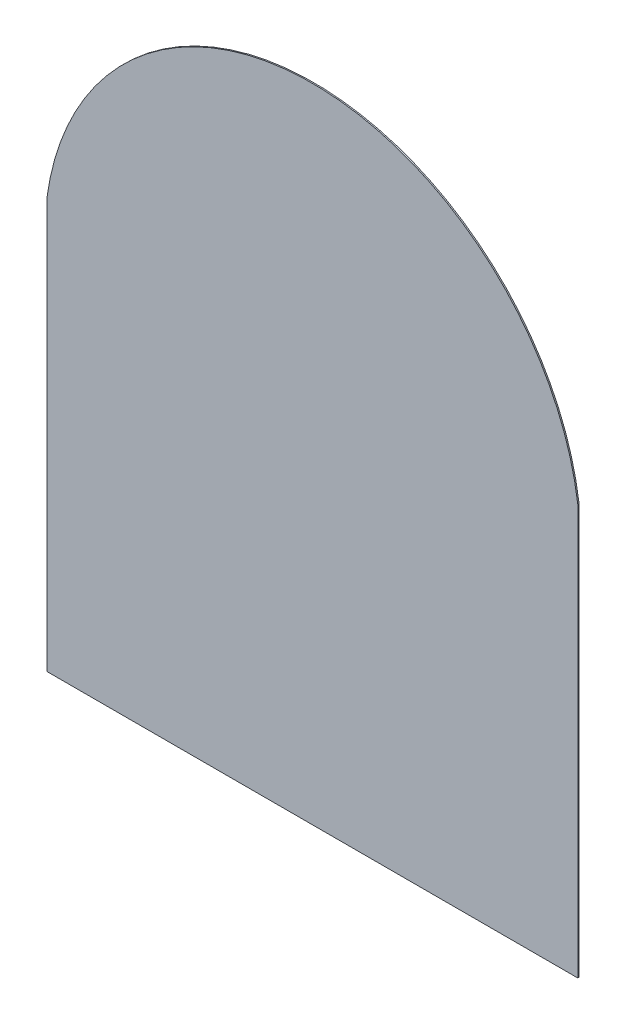
from build123d import *

# Parameters (mm, degrees)
BOSS_EXTRUDE1_DEPTH = 2.5


with BuildPart() as part:
    # Sketch1 → Boss-Extrude1 (new body, symmetric)
    with BuildSketch(Plane.XY):
        with BuildLine():
            Line((1030, 796), (1030, -796))
            Line((1030, -796), (-1030, -796))
            Line((-1030, -796), (-1030, 796))
            ThreePointArc((-1030, 796), (0, 1696), (1030, 796))
        make_face()
    extrude(amount=BOSS_EXTRUDE1_DEPTH, both=True)


solid = part.part
